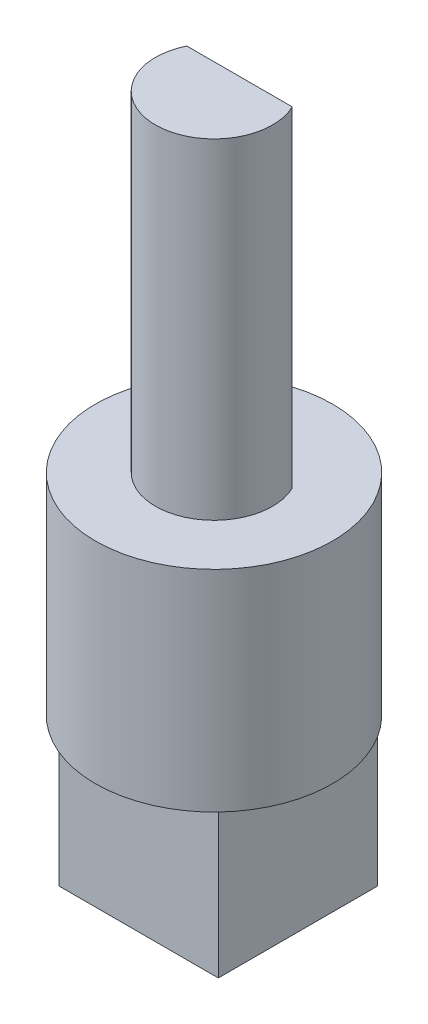
from build123d import *

# Parameters (mm, degrees)
SKETCH1_W           = 5.3
SKETCH1_H           = 5.3
BOSS_EXTRUDE1_DEPTH = 5
SKETCH2_R           = 3.95
BOSS_EXTRUDE2_DEPTH = 7
SKETCH3_R           = 1.95
BOSS_EXTRUDE3_DEPTH = 11
CUT_EXTRUDE1_DEPTH  = 11


with BuildPart() as part:
    # Sketch1 → Boss-Extrude1 (new body)
    with BuildSketch(Plane(origin=(0, 0, 0), x_dir=(1, 0, 0), z_dir=(0, 1, 0))):
        with Locations((0, 0.143071786)):
            Rectangle(SKETCH1_W, SKETCH1_H)
    extrude(amount=BOSS_EXTRUDE1_DEPTH)

    # Sketch2 → Boss-Extrude2 (add)
    with BuildSketch(Plane(origin=(0, 5, 0), x_dir=(1, 0, 0), z_dir=(0, 1, 0))):
        Circle(SKETCH2_R)
    extrude(amount=BOSS_EXTRUDE2_DEPTH)

    # Sketch3 → Boss-Extrude3 (add)
    with BuildSketch(Plane(origin=(0, 12, 0), x_dir=(1, 0, 0), z_dir=(0, 1, 0))):
        Circle(SKETCH3_R)
    extrude(amount=BOSS_EXTRUDE3_DEPTH)

    # Sketch4 → Cut-Extrude1 (cut)
    with BuildSketch(Plane(origin=(0, 23, 0), x_dir=(1, 0, 0), z_dir=(0, 1, 0))):
        with BuildLine():
            Line((-1.754992877, 0.85), (1.754992877, 0.85))
            ThreePointArc((1.754992877, 0.85), (0, 1.95), (-1.754992877, 0.85))
        make_face()
    extrude(amount=-CUT_EXTRUDE1_DEPTH, mode=Mode.SUBTRACT)


solid = part.part
